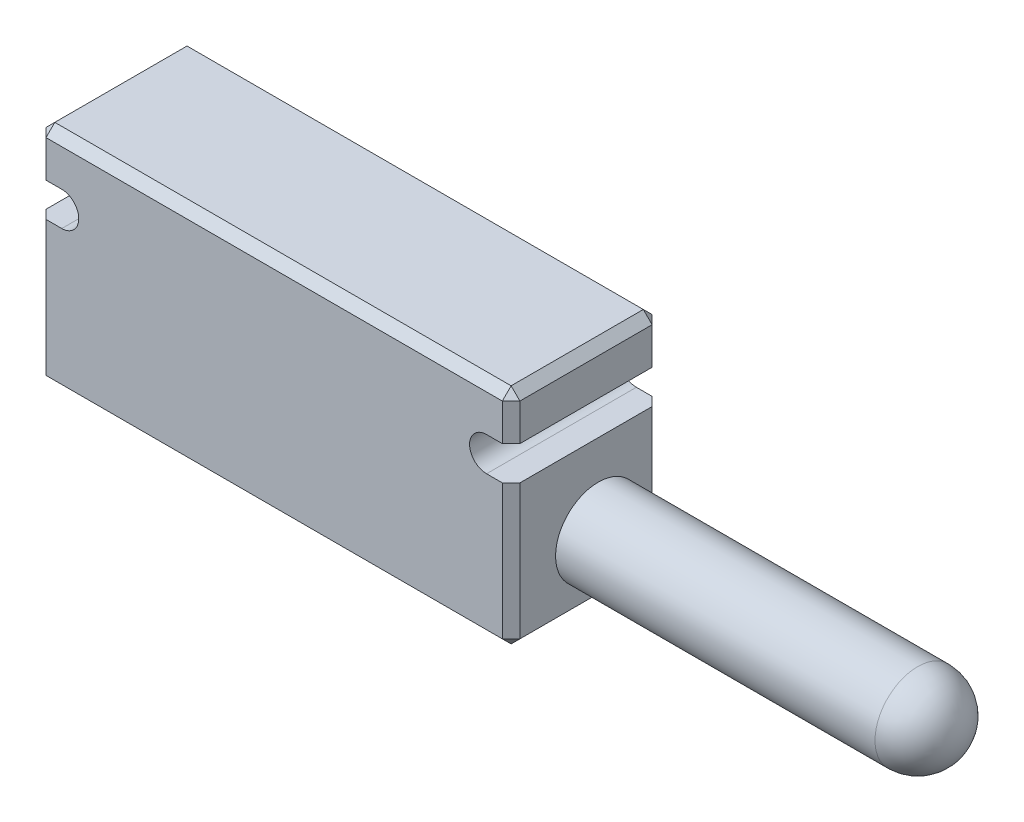
from build123d import *

# Parameters (mm, degrees)
SKETCH1_W                = 26.92
SKETCH1_H                = 12.7
BOSS_EXTRUDE1_DEPTH      = 4.95
BOSS_EXTRUDE1_DEPTH_BACK = 3.56
CUT_EXTRUDE1_DEPTH       = 9.51
SKETCH3_R                = 2.425
BOSS_EXTRUDE2_DEPTH      = 20.57
FILLET1_R                = 2.425
CHAMFER1_SIZE            = 0.5


with BuildPart() as part:
    # Sketch1 → Boss-Extrude1 (new body, two sides)
    with BuildSketch(Plane.XY) as boss_extrude1_sk:
        Rectangle(SKETCH1_W, SKETCH1_H)
    extrude(amount=BOSS_EXTRUDE1_DEPTH)
    extrude(boss_extrude1_sk.sketch, amount=-BOSS_EXTRUDE1_DEPTH_BACK)

    # Sketch2 → Cut-Extrude1 (cut, through all)
    with BuildSketch(Plane.XY.offset(4.95)):
        with BuildLine():
            Line((-12.065, 1.825), (-13.46, 1.825))
            ThreePointArc((-13.46, 1.825), (-14.425, 2.79), (-13.46, 3.755))
            Line((-13.46, 3.755), (-12.065, 3.755))
            ThreePointArc((-12.065, 3.755), (-11.1, 2.79), (-12.065, 1.825))
        make_face()
        with BuildLine():
            Line((12.065, 1.825), (13.46, 1.825))
            ThreePointArc((13.46, 1.825), (14.425, 2.79), (13.46, 3.755))
            Line((13.46, 3.755), (12.065, 3.755))
            ThreePointArc((12.065, 3.755), (11.1, 2.79), (12.065, 1.825))
        make_face()
    extrude(amount=-CUT_EXTRUDE1_DEPTH, mode=Mode.SUBTRACT)

    # Sketch3 → Boss-Extrude2 (add)
    with BuildSketch(Plane(origin=(13.46, 0, 0), x_dir=(0, 0, -1), z_dir=(1, 0, 0))):
        with Locations((0, -2.79)):
            Circle(SKETCH3_R)
    extrude(amount=BOSS_EXTRUDE2_DEPTH)

    # Fillet1
    fillet1_edges = [part.edges().sort_by_distance(p)[0] for p in [
        (34.03, -2.79, 2.425),
    ]]
    fillet(fillet1_edges, radius=FILLET1_R)

    # Chamfer1
    chamfer1_edges = [part.edges().sort_by_distance(p)[0] for p in [
        (13.46, 6.35, 0.695),
        (13.46, 5.0525, -3.56),
        (0, 6.35, -3.56),
        (-13.46, 6.35, 0.695),
        (13.46, 5.0525, 4.95),
        (0, 6.35, 4.95),
        (-13.46, 5.0525, 4.95),
        (13.46, -6.35, 0.695),
        (-13.46, -2.2625, -3.56),
        (13.46, -2.2625, -3.56),
        (0, -6.35, -3.56),
        (-13.46, -6.35, 0.695),
        (13.46, -2.2625, 4.95),
        (0, -6.35, 4.95),
        (-13.46, -2.2625, 4.95),
    ]]
    chamfer(chamfer1_edges, length=CHAMFER1_SIZE)


solid = part.part
